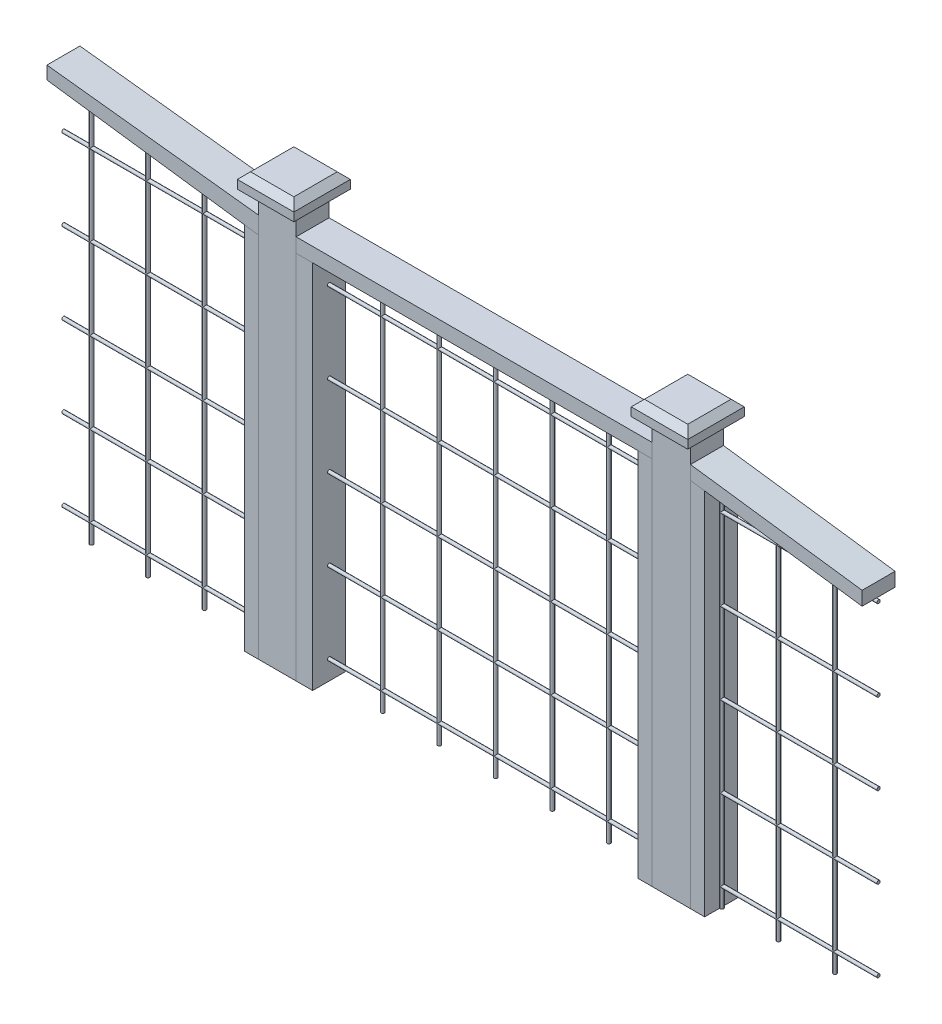
from build123d import *

# Parameters (mm, degrees)
SKETCH2_W                        = 100.776454278
SKETCH2_H                        = 1172.012262384
POSTS_DEPTH                      = 44.45
SKETCH2_W_2                      = 103.490918788
POSTS_2_DEPTH                    = 44.45
TOP_2X4_DEPTH                    = 44.45
TOP_2X4_2_DEPTH                  = 44.45
SIDE_VERTICALS_DEPTH             = 44.45
SIDE_VERTICALS_2_DEPTH           = 44.45
SKETCH5_W                        = 959.05267275
SKETCH5_H                        = 38.305522828
GATE_FRAME_TOP_DEPTH             = 44.45
GATE_SIDE_VERTICALS_DEPTH        = 44.45
GATE_SIDE_VERTICALS_2_DEPTH      = 44.45
SKETCH9_R                        = 4.510522668
GATE_AND_RIGHT_VERT_WIRE_DEPTH   = 998.839638219
GATE_AND_RIGHT_VERT_WIRE_2_DEPTH = 998.839638219
GATE_AND_RIGHT_VERT_WIRE_3_DEPTH = 998.839638219
GATE_AND_RIGHT_VERT_WIRE_4_DEPTH = 998.839638219
GATE_AND_RIGHT_VERT_WIRE_5_DEPTH = 998.839638219
GATE_AND_RIGHT_VERT_WIRE_6_DEPTH = 998.839638219
GATE_AND_RIGHT_VERT_WIRE_7_DEPTH = 998.839638219
GATE_AND_RIGHT_VERT_WIRE_8_DEPTH = 998.839638219
GATE_AND_RIGHT_VERT_WIRE_9_DEPTH = 998.839638219
LEFT_VERT_WIRE_REACH             = 2416.583
SKETCH11_R                       = 4.532222792
LEFT_VERT_WIRE_DIRECTION_2_DEPTH = 998.839638
HORIZONTAL_START                 = -1664.874327
SKETCH12_R                       = 4.447444092
HORIZONTAL_WIRE_DEPTH            = 2197.852307
HORIZONTAL_WIRE_2_DEPTH          = 2197.852307
HORIZONTAL_WIRE_3_DEPTH          = 2197.852307
HORIZONTAL_WIRE_4_DEPTH          = 2197.852307
HORIZONTAL_WIRE_5_DEPTH          = 2197.852307
SKETCH13_R                       = 4.510522668
CUT_EXTRUDE1_DEPTH               = 21.336
SKETCH14_W                       = 103.490918788
SKETCH14_H                       = 88.9
SKETCH14_W_2                     = 100.776454278
CUT_EXTRUDE2_DEPTH               = 71.12
SKETCH23_W                       = 152.4
SKETCH23_H                       = 152.4
BOSS_EXTRUDE1_DEPTH              = 40.64
BOSS_EXTRUDE1_2_DEPTH            = 40.64
CHAMFER1_SIZE                    = 17.78
CHAMFER2_SIZE                    = 17.78


with BuildPart() as part:
    # Sketch2 → Posts (new, symmetric)
    with BuildSketch(Plane.XY):
        with Locations((621.27547247, 586.006131192)):
            Rectangle(SKETCH2_W, SKETCH2_H)
    extrude(amount=POSTS_DEPTH, both=True)


with BuildPart() as body_2:
    # Sketch2 → Posts 2 (new, symmetric)
    with BuildSketch(Plane.XY):
        with Locations((1683.360010639, 586.006131192)):
            Rectangle(SKETCH2_W_2, SKETCH2_H)
    extrude(amount=POSTS_2_DEPTH, both=True)


with BuildPart() as body_3:
    # Sketch3 → Top 2x4 (new, symmetric)
    with BuildSketch(Plane.XY):
        Polygon((570.887245331, 1037.145161047), (0, 1102.372368395), (0, 1067.425386357), (570.887245331, 990.607252759), align=None)
    extrude(amount=TOP_2X4_DEPTH, both=True)


with BuildPart() as body_4:
    # Sketch3 → Top 2x4 2 (new, symmetric)
    with BuildSketch(Plane.XY):
        Polygon((1735.105470033, 1037.145161047), (2197.85230682, 974.878314798), (2197.85230682, 937.569835403), (1735.105470033, 999.836681652), align=None)
    extrude(amount=TOP_2X4_2_DEPTH, both=True)


with BuildPart() as body_5:
    # Sketch4 → Side Verticals (new, symmetric)
    with BuildSketch(Plane.XY):
        Polygon((532.977980241, 995.708293314), (532.977980241, 0), (570.887245331, 0), (570.887245331, 990.607252759), align=None)
    extrude(amount=SIDE_VERTICALS_DEPTH, both=True)


with BuildPart() as body_6:
    # Sketch4 → Side Verticals 2 (new, symmetric)
    with BuildSketch(Plane.XY):
        Polygon((1735.105470033, 0), (1773.372461411, 0), (1773.372461411, 994.687505733), (1735.105470033, 999.836681652), align=None)
    extrude(amount=SIDE_VERTICALS_2_DEPTH, both=True)


with BuildPart() as body_7:
    # Sketch5 → Gate Frame Top (new, symmetric)
    with BuildSketch(Plane.XY):
        with Locations((1151.421194056, 1017.992399633)):
            Rectangle(SKETCH5_W, SKETCH5_H)
    extrude(amount=GATE_FRAME_TOP_DEPTH, both=True)


with BuildPart() as body_8:
    # Sketch7 → Gate Side Verticals (new, symmetric)
    with BuildSketch(Plane.XY):
        Polygon((671.894857681, 998.839638219), (716.436459545, 998.839638219), (716.436459545, 0), (671.663699609, 0), align=None)
    extrude(amount=GATE_SIDE_VERTICALS_DEPTH, both=True)


with BuildPart() as body_9:
    # Sketch7 → Gate Side Verticals 2 (new, symmetric)
    with BuildSketch(Plane.XY):
        Polygon((1630.947530431, 998.839638219), (1631.614551245, 0), (1593.334739356, 0), (1593.334739356, 998.839638219), align=None)
    extrude(amount=GATE_SIDE_VERTICALS_2_DEPTH, both=True)


with BuildPart() as body_10:
    # Sketch9 → Gate and Right Vert Wire (new body)
    with BuildSketch(Plane(origin=(0, 998.839638219, 0), x_dir=(-1, 0, 0), z_dir=(0, -1, 0))):
        with Locations(Location((-861.216459545, 0, 0), (0, 0, 270))):
            Circle(SKETCH9_R)
    extrude(amount=GATE_AND_RIGHT_VERT_WIRE_DEPTH)


with BuildPart() as body_11:
    # Sketch9 → Gate and Right Vert Wire 2 (new body)
    with BuildSketch(Plane(origin=(0, 998.839638219, 0), x_dir=(-1, 0, 0), z_dir=(0, -1, 0))):
        with Locations(Location((-1013.616459545, 0, 0), (0, 0, 270))):
            Circle(SKETCH9_R)
    extrude(amount=GATE_AND_RIGHT_VERT_WIRE_2_DEPTH)


with BuildPart() as body_12:
    # Sketch9 → Gate and Right Vert Wire 3 (new body)
    with BuildSketch(Plane(origin=(0, 998.839638219, 0), x_dir=(-1, 0, 0), z_dir=(0, -1, 0))):
        with Locations(Location((-1166.016459545, 0, 0), (0, 0, 270))):
            Circle(SKETCH9_R)
    extrude(amount=GATE_AND_RIGHT_VERT_WIRE_3_DEPTH)


with BuildPart() as body_13:
    # Sketch9 → Gate and Right Vert Wire 4 (new body)
    with BuildSketch(Plane(origin=(0, 998.839638219, 0), x_dir=(-1, 0, 0), z_dir=(0, -1, 0))):
        with Locations(Location((-1318.416459545, 0, 0), (0, 0, 270))):
            Circle(SKETCH9_R)
    extrude(amount=GATE_AND_RIGHT_VERT_WIRE_4_DEPTH)


with BuildPart() as body_14:
    # Sketch9 → Gate and Right Vert Wire 5 (new body)
    with BuildSketch(Plane(origin=(0, 998.839638219, 0), x_dir=(-1, 0, 0), z_dir=(0, -1, 0))):
        with Locations(Location((-1470.816459545, 0, 0), (0, 0, 270))):
            Circle(SKETCH9_R)
    extrude(amount=GATE_AND_RIGHT_VERT_WIRE_5_DEPTH)


with BuildPart() as body_15:
    # Sketch9 → Gate and Right Vert Wire 6 (new body)
    with BuildSketch(Plane(origin=(0, 998.839638219, 0), x_dir=(-1, 0, 0), z_dir=(0, -1, 0))):
        with Locations(Location((-1623.216459545, 0, 0), (0, 0, 270))):
            Circle(SKETCH9_R)
    extrude(amount=GATE_AND_RIGHT_VERT_WIRE_6_DEPTH)


with BuildPart() as body_16:
    # Sketch9 → Gate and Right Vert Wire 7 (new body)
    with BuildSketch(Plane(origin=(0, 998.839638219, 0), x_dir=(-1, 0, 0), z_dir=(0, -1, 0))):
        with Locations(Location((-1775.616459545, 0, 0), (0, 0, 270))):
            Circle(SKETCH9_R)
    extrude(amount=GATE_AND_RIGHT_VERT_WIRE_7_DEPTH)


with BuildPart() as body_17:
    # Sketch9 → Gate and Right Vert Wire 8 (new body)
    with BuildSketch(Plane(origin=(0, 998.839638219, 0), x_dir=(-1, 0, 0), z_dir=(0, -1, 0))):
        with Locations(Location((-1928.016459545, 0, 0), (0, 0, 270))):
            Circle(SKETCH9_R)
    extrude(amount=GATE_AND_RIGHT_VERT_WIRE_8_DEPTH)


with BuildPart() as body_18:
    # Sketch9 → Gate and Right Vert Wire 9 (new body)
    with BuildSketch(Plane(origin=(0, 998.839638219, 0), x_dir=(-1, 0, 0), z_dir=(0, -1, 0))):
        with Locations(Location((-2080.416459545, 0, 0), (0, 0, 270))):
            Circle(SKETCH9_R)
    extrude(amount=GATE_AND_RIGHT_VERT_WIRE_9_DEPTH)

    # Sketch13 → Cut-Extrude1 (cut)
    with BuildSketch(Plane(origin=(0, 998.839638219, 0), x_dir=(1, 0, 0), z_dir=(0, 1, 0))):
        with Locations(Location((2080.416459545, 0, 0), (0, 0, 270))):
            Circle(SKETCH13_R)
    extrude(amount=-CUT_EXTRUDE1_DEPTH, mode=Mode.SUBTRACT)


with BuildPart() as body_19:
    # Left Vert Wire: up to this plane
    left_vert_wire_end = Plane(origin=(0, 1067.425386357, 44.45), z_dir=(0.13335732463892713, 0.9910680218658797, 0))
    # Sketch11 → Left Vert Wire (new, up to the surface)
    with BuildSketch(Plane.XZ.offset(-998.839638219), mode=Mode.PRIVATE) as left_vert_wire_sk1:
        with Locations((380.577980241, 0)):
            Circle(SKETCH11_R)
    left_vert_wire_tool1 = split(extrude(left_vert_wire_sk1.sketch, amount=-LEFT_VERT_WIRE_REACH, mode=Mode.PRIVATE), bisect_by=left_vert_wire_end, keep=Keep.BOTH, mode=Mode.PRIVATE)
    add(left_vert_wire_tool1.solids().sort_by_distance((380.57798, 998.839638, 0))[0])
    # Sketch11 → Left Vert Wire (new, up to the surface)
    with BuildSketch(Plane.XZ.offset(-998.839638219), mode=Mode.PRIVATE) as left_vert_wire_sk2:
        with Locations((228.177980241, 0)):
            Circle(SKETCH11_R)
    left_vert_wire_tool2 = split(extrude(left_vert_wire_sk2.sketch, amount=-LEFT_VERT_WIRE_REACH, mode=Mode.PRIVATE), bisect_by=left_vert_wire_end, keep=Keep.BOTH, mode=Mode.PRIVATE)
    add(left_vert_wire_tool2.solids().sort_by_distance((228.17798, 998.839638, 0))[0])
    # Sketch11 → Left Vert Wire (new, up to the surface)
    with BuildSketch(Plane.XZ.offset(-998.839638219), mode=Mode.PRIVATE) as left_vert_wire_sk3:
        with Locations((75.777980241, 0)):
            Circle(SKETCH11_R)
    left_vert_wire_tool3 = split(extrude(left_vert_wire_sk3.sketch, amount=-LEFT_VERT_WIRE_REACH, mode=Mode.PRIVATE), bisect_by=left_vert_wire_end, keep=Keep.BOTH, mode=Mode.PRIVATE)
    add(left_vert_wire_tool3.solids().sort_by_distance((75.77798, 998.839638, 0))[0])

    # Sketch11 → Left Vert Wire direction 2 (add)
    with BuildSketch(Plane.XZ.offset(-998.839638219)):
        with Locations((380.577980241, 0)):
            Circle(SKETCH11_R)
        with Locations((228.177980241, 0)):
            Circle(SKETCH11_R)
        with Locations((75.777980241, 0)):
            Circle(SKETCH11_R)
    extrude(amount=LEFT_VERT_WIRE_DIRECTION_2_DEPTH)


with BuildPart() as body_20:
    # Sketch12 → Horizontal Wire (new body)
    with BuildSketch(Plane.ZY.offset(-532.977980241).offset(HORIZONTAL_START)):
        with Locations(Location((0, 926.073219901, 0), (0, 0, 180))):
            Circle(SKETCH12_R)
    extrude(amount=HORIZONTAL_WIRE_DEPTH)


with BuildPart() as body_21:
    # Sketch12 → Horizontal Wire 2 (new body)
    with BuildSketch(Plane.ZY.offset(-532.977980241).offset(HORIZONTAL_START)):
        with Locations(Location((0, 707.633219901, 0), (0, 0, 180))):
            Circle(SKETCH12_R)
    extrude(amount=HORIZONTAL_WIRE_2_DEPTH)


with BuildPart() as body_22:
    # Sketch12 → Horizontal Wire 3 (new body)
    with BuildSketch(Plane.ZY.offset(-532.977980241).offset(HORIZONTAL_START)):
        with Locations(Location((0, 489.193219901, 0), (0, 0, 180))):
            Circle(SKETCH12_R)
    extrude(amount=HORIZONTAL_WIRE_3_DEPTH)


with BuildPart() as body_23:
    # Sketch12 → Horizontal Wire 4 (new body)
    with BuildSketch(Plane.ZY.offset(-532.977980241).offset(HORIZONTAL_START)):
        with Locations(Location((0, 270.753219901, 0), (0, 0, 180))):
            Circle(SKETCH12_R)
    extrude(amount=HORIZONTAL_WIRE_4_DEPTH)


with BuildPart() as body_24:
    # Sketch12 → Horizontal Wire 5 (new body)
    with BuildSketch(Plane.ZY.offset(-532.977980241).offset(HORIZONTAL_START)):
        with Locations(Location((0, 52.313219901, 0), (0, 0, 180))):
            Circle(SKETCH12_R)
    extrude(amount=HORIZONTAL_WIRE_5_DEPTH)


with BuildPart() as cut_extrude2_tool:
    # Sketch14 → Cut-Extrude2 (new body)
    with BuildSketch(Plane(origin=(0, 1172.012262384, 0), x_dir=(1, 0, 0), z_dir=(0, 1, 0))):
        with Locations((1683.360010639, 0)):
            Rectangle(SKETCH14_W, SKETCH14_H)
        with Locations((621.27547247, 0)):
            Rectangle(SKETCH14_W_2, SKETCH14_H)
    extrude(amount=-CUT_EXTRUDE2_DEPTH)


with BuildPart() as part_1:
    add(part.part)

    # Cut-Extrude2: cut by cut_extrude2_tool
    add(cut_extrude2_tool.part, mode=Mode.SUBTRACT)


with BuildPart() as body_2_1:
    add(body_2.part)

    # Cut-Extrude2: cut by cut_extrude2_tool
    add(cut_extrude2_tool.part, mode=Mode.SUBTRACT)


with BuildPart() as body_25:
    # Sketch23 → Boss-Extrude1 (new body)
    with BuildSketch(Plane(origin=(0, 1100.892262384, 0), x_dir=(1, 0, 0), z_dir=(0, 1, 0))):
        with Locations((1683.360010639, 0)):
            Rectangle(SKETCH23_W, SKETCH23_H)
    extrude(amount=BOSS_EXTRUDE1_DEPTH)

    # Chamfer2
    chamfer2_edges = [body_25.edges().sort_by_distance(p)[0] for p in [
        (1607.160010639, 1141.532262384, 0),
        (1683.360010639, 1141.532262384, 76.2),
        (1759.560010639, 1141.532262384, 0),
        (1683.360010639, 1141.532262384, -76.2),
    ]]
    chamfer(chamfer2_edges, length=CHAMFER2_SIZE)


with BuildPart() as body_26:
    # Sketch23 → Boss-Extrude1 2 (new body)
    with BuildSketch(Plane(origin=(0, 1100.892262384, 0), x_dir=(1, 0, 0), z_dir=(0, 1, 0))):
        with Locations((621.27547247, 0)):
            Rectangle(SKETCH23_W, SKETCH23_H)
    extrude(amount=BOSS_EXTRUDE1_2_DEPTH)

    # Chamfer1
    chamfer1_edges = [body_26.edges().sort_by_distance(p)[0] for p in [
        (545.07547247, 1141.532262384, 0),
        (621.27547247, 1141.532262384, 76.2),
        (697.47547247, 1141.532262384, 0),
        (621.27547247, 1141.532262384, -76.2),
    ]]
    chamfer(chamfer1_edges, length=CHAMFER1_SIZE)


solid = Compound([body_3.part, body_4.part, body_5.part, body_6.part, body_7.part, body_8.part, body_9.part, body_10.part, body_11.part, body_12.part, body_13.part, body_14.part, body_15.part, body_16.part, body_17.part, body_18.part, body_19.part, body_20.part, body_21.part, body_22.part, body_23.part, body_24.part, part_1.part, body_2_1.part, body_25.part, body_26.part])
